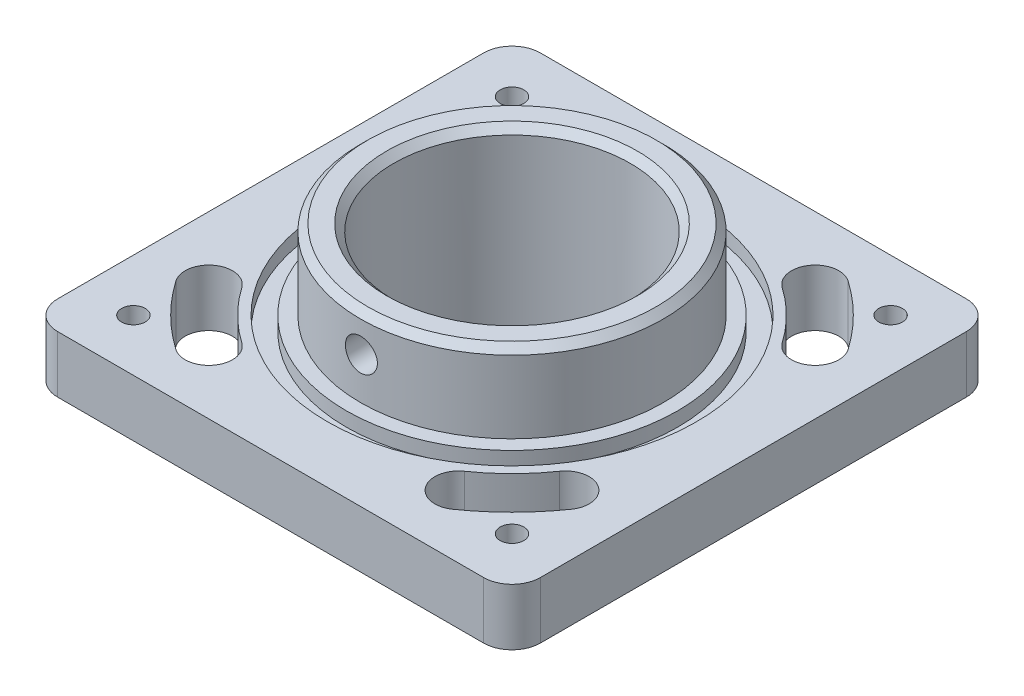
from build123d import *

# Parameters (mm, degrees)
ESQUISSE1_W                = 161.925
ESQUISSE1_H                = 161.925
ESQUISSE1_R                = 39.6875
BOSS_EXTRU_1_DEPTH         = 19.05
TROU_TARAUD_3_8_161_D      = 7.9375
ESQUISSE4_R                = 61.9125
ESQUISSE4_R_2              = 55.5625
ENL_V_MAT_EXTRU_1_DEPTH    = 4.7625
ESQUISSE5_R                = 50.8
ESQUISSE5_R_2              = 39.6875
BOSS_EXTRU_2_DEPTH         = 26.67
CONG_1_R                   = 9.525
TROU_TARAUD_1_2_131_REACH  = 158.932
TROU_TARAUD_1_2_131_BORE_R = 5.35813
CHANFREIN2_SIZE            = 2.38125
ESQUISSE11_R               = 53.975
ESQUISSE11_R_2             = 39.6875
BOSS_EXTRU_3_DEPTH         = 19.05
CHANFREIN4_SIZE            = 2.38125


with BuildPart() as part:
    # Esquisse1 → Boss.-Extru.1 (new body)
    with BuildSketch(Plane(origin=(0, 0, 0), x_dir=(1, 0, 0), z_dir=(0, 1, 0))):
        Rectangle(ESQUISSE1_W, ESQUISSE1_H)
        with Locations(Location((0, 0, 0), (0, 0, 270))):
            Circle(ESQUISSE1_R, mode=Mode.SUBTRACT)
        with BuildLine():
            ThreePointArc((-46.438182228, 66.320597386), (-57.249132772, 57.249132772), (-66.320597386, 46.438182228))
            ThreePointArc((-66.320597386, 46.438182228), (-64.371340998, 35.383399913), (-53.316558683, 37.332656301))
            ThreePointArc((-53.316558683, 37.332656301), (-46.02381262, 46.02381262), (-37.332656301, 53.316558683))
            ThreePointArc((-37.332656301, 53.316558683), (-35.383399913, 64.371340998), (-46.438182228, 66.320597386))
        make_face(mode=Mode.SUBTRACT)
        with BuildLine():
            ThreePointArc((66.320597386, 46.438182228), (57.249132772, 57.249132772), (46.438182228, 66.320597386))
            ThreePointArc((46.438182228, 66.320597386), (35.383399913, 64.371340998), (37.332656301, 53.316558683))
            ThreePointArc((37.332656301, 53.316558683), (46.02381262, 46.02381262), (53.316558683, 37.332656301))
            ThreePointArc((53.316558683, 37.332656301), (64.371340998, 35.383399913), (66.320597386, 46.438182228))
        make_face(mode=Mode.SUBTRACT)
        with BuildLine():
            ThreePointArc((46.438182228, -66.320597386), (57.249132772, -57.249132772), (66.320597386, -46.438182228))
            ThreePointArc((66.320597386, -46.438182228), (64.371340998, -35.383399913), (53.316558683, -37.332656301))
            ThreePointArc((53.316558683, -37.332656301), (46.02381262, -46.02381262), (37.332656301, -53.316558683))
            ThreePointArc((37.332656301, -53.316558683), (35.383399913, -64.371340998), (46.438182228, -66.320597386))
        make_face(mode=Mode.SUBTRACT)
        with BuildLine():
            ThreePointArc((-66.320597386, -46.438182228), (-57.249132772, -57.249132772), (-46.438182228, -66.320597386))
            ThreePointArc((-46.438182228, -66.320597386), (-35.383399913, -64.371340998), (-37.332656301, -53.316558683))
            ThreePointArc((-37.332656301, -53.316558683), (-46.02381262, -46.02381262), (-53.316558683, -37.332656301))
            ThreePointArc((-53.316558683, -37.332656301), (-64.371340998, -35.383399913), (-66.320597386, -46.438182228))
        make_face(mode=Mode.SUBTRACT)
    extrude(amount=-BOSS_EXTRU_1_DEPTH)

    # Trou taraudé 3/8-161 (through all)
    with Locations(Plane(origin=(0, 0, 0), x_dir=(1, 0, 0), z_dir=(0, 1, 0))):
        with Locations((-63.5, 63.5), (63.5, 63.5), (-63.5, -63.5), (63.5, -63.5)):
            Hole(TROU_TARAUD_3_8_161_D / 2)

    # Esquisse4 → Enlèv. mat.-Extru.1 (cut)
    with BuildSketch(Plane(origin=(0, 0, 0), x_dir=(1, 0, 0), z_dir=(0, 1, 0))):
        with Locations(Location((0, 0, 0), (0, 0, 270))):
            Circle(ESQUISSE4_R)
        with Locations(Location((0, 0, 0), (0, 0, 270))):
            Circle(ESQUISSE4_R_2, mode=Mode.SUBTRACT)
    extrude(amount=-ENL_V_MAT_EXTRU_1_DEPTH, mode=Mode.SUBTRACT)

    # Esquisse5 → Boss.-Extru.2 (add)
    with BuildSketch(Plane(origin=(0, 0, 0), x_dir=(1, 0, 0), z_dir=(0, 1, 0))):
        with Locations(Location((0, 0, 0), (0, 0, 270))):
            Circle(ESQUISSE5_R)
        with Locations(Location((0, 0, 0), (0, 0, 270))):
            Circle(ESQUISSE5_R_2, mode=Mode.SUBTRACT)
    extrude(amount=BOSS_EXTRU_2_DEPTH)

    # Congé1
    cong_1_edges = [part.edges().sort_by_distance(p)[0] for p in [
        (80.9625, -9.525, 80.9625),
        (-80.9625, -9.525, 80.9625),
        (-80.9625, -9.525, -80.9625),
        (80.9625, -9.525, -80.9625),
    ]]
    fillet(cong_1_edges, radius=CONG_1_R)

    # Trou taraudé 1/2-131 bore → Trou taraudé 1/2-131 (cut, up to next)
    with BuildSketch(Plane.XY.offset(50.8), mode=Mode.PRIVATE) as trou_taraud_1_2_131_sk1:
        with Locations((0, 13.97)):
            Circle(TROU_TARAUD_1_2_131_BORE_R)
    trou_taraud_1_2_131_tool1 = extrude(trou_taraud_1_2_131_sk1.sketch, amount=-TROU_TARAUD_1_2_131_REACH, mode=Mode.PRIVATE) & part.part
    add(trou_taraud_1_2_131_tool1.solids().sort_by_distance((0, 13.97, 50.8))[0], mode=Mode.SUBTRACT)

    # Chanfrein2
    chanfrein2_edges = [part.edges().sort_by_distance(p)[0] for p in [
        (0, 26.67, -50.8),
        (0, 26.67, -39.6875),
    ]]
    chamfer(chanfrein2_edges, length=CHANFREIN2_SIZE)

    # Esquisse11 → Boss.-Extru.3 (add)
    with BuildSketch(Plane(origin=(0, -19.05, 0), x_dir=(-1, 0, 0), z_dir=(0, -1, 0))):
        with Locations(Location((0, 0, 0), (0, 0, 90))):
            Circle(ESQUISSE11_R)
        with Locations(Location((0, 0, 0), (0, 0, 270))):
            Circle(ESQUISSE11_R_2, mode=Mode.SUBTRACT)
    extrude(amount=BOSS_EXTRU_3_DEPTH)

    # Chanfrein4
    chanfrein4_edges = [part.edges().sort_by_distance(p)[0] for p in [
        (0, -38.1, -39.6875),
    ]]
    chamfer(chanfrein4_edges, length=CHANFREIN4_SIZE)


solid = part.part
